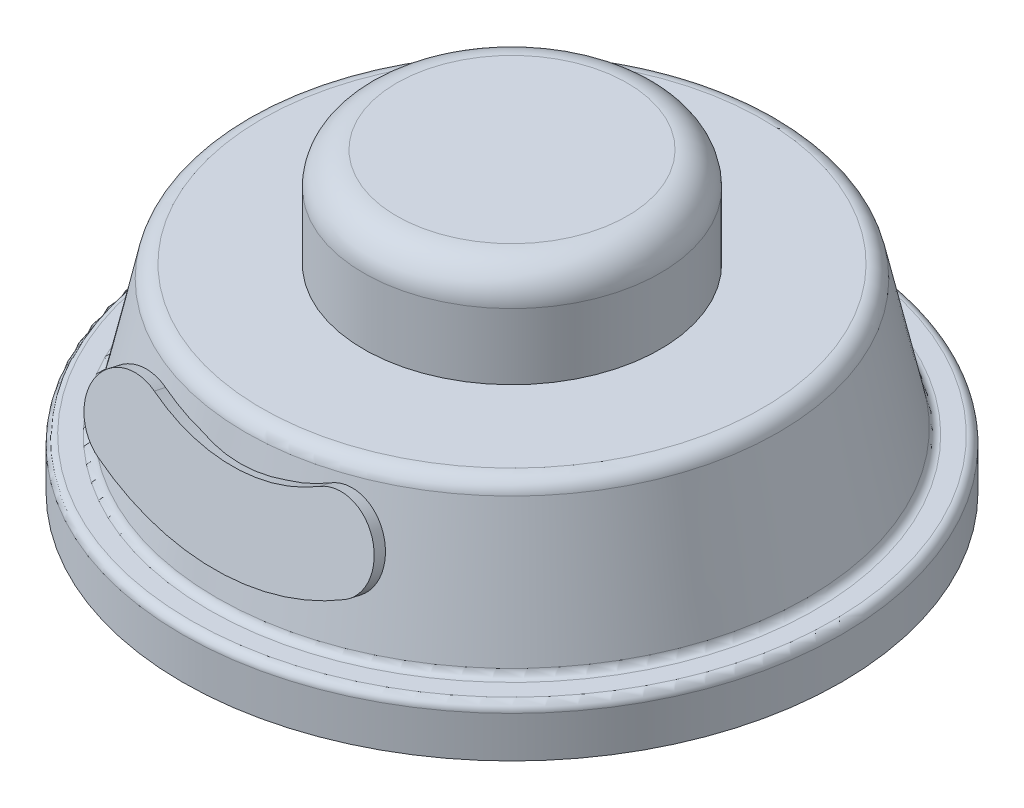
from build123d import *

# Parameters (mm, degrees)
SKETCH_1_R      = 20
EXTRUDE_1_DEPTH = 3
SKETCH_4_R      = 9
EXTRUDE_2_DEPTH = 6
FILLET_1_R      = 2
FILLET_2_R      = 1
FILLET_3_R      = 0.5
EXTRUDE_START   = -0.2
SKETCH_6_W      = 2
SKETCH_6_H      = 2
EXTRUDE_3_DEPTH = 0.7


with BuildPart() as part:
    # 草图1 → 凸台-拉伸1 (new body)
    with BuildSketch(Plane(origin=(0, 0, 0), x_dir=(1, 0, 0), z_dir=(0, 1, 0))):
        Circle(SKETCH_1_R)
    extrude(amount=EXTRUDE_1_DEPTH)

    # 草图3 → 旋转1 (revolve)
    with BuildSketch(Plane.XY):
        Polygon((0, 3), (-18, 3), (-16, 12), (0, 12), align=None)
    revolve(axis=Axis((0, 12, 0), (0, -1, 0)))

    # 草图4 → 凸台-拉伸2 (add)
    with BuildSketch(Plane(origin=(0, 12, 0), x_dir=(1, 0, 0), z_dir=(0, 1, 0))):
        Circle(SKETCH_4_R)
    extrude(amount=EXTRUDE_2_DEPTH)

    # 圆角1
    fillet_1_edges = [part.edges().sort_by_distance(p)[0] for p in [
        (-9, 18, 0),
    ]]
    fillet(fillet_1_edges, radius=FILLET_1_R)

    # 圆角2
    fillet_2_edges = [part.edges().sort_by_distance(p)[0] for p in [
        (16, 12, 0),
    ]]
    fillet(fillet_2_edges, radius=FILLET_2_R)

    # 草图5 → 切除-旋转1 (revolve, cut)
    with BuildSketch(Plane.XY):
        with BuildLine():
            Line((-17.5, 0), (-15, 0))
            ThreePointArc((-15, 0), (-16.767766953, 0.732233047), (-17.5, 2.5))
            Line((-17.5, 2.5), (-17.5, 0))
        make_face()
        with BuildLine():
            Line((-10, 3.5), (-13.370759884, 0.603799419))
            ThreePointArc((-13.370759884, 0.603799419), (-14.131236929, 0.155804887), (-15, 0))
            Line((-15, 0), (0, 0))
            Line((0, 0), (0, 2))
            ThreePointArc((0, 2), (-5.055937104, 2.377085973), (-10, 3.5))
        make_face()
    revolve(axis=Axis((0, 2, 0), (0, -1, 0)), mode=Mode.SUBTRACT)

    # 圆角3
    fillet_3_edges = [part.edges().sort_by_distance(p)[0] for p in [
        (-20, 3, 0),
        (18, 3, 0),
    ]]
    fillet(fillet_3_edges, radius=FILLET_3_R)

    # 草图6 → 凸台-拉伸3 (add)
    with BuildSketch(Plane(origin=(0, 3.952941176, 17.788235294), x_dir=(1, 0, 0), z_dir=(0, 0.216930458, 0.97618706)).offset(EXTRUDE_START)):
        with BuildLine():
            ThreePointArc((-7.488132587, 2.917536085), (0, 0.933042267), (7.488132587, 2.917536085))
            ThreePointArc((7.488132587, 2.917536085), (8.421871934, 6.327540606), (5.011867413, 7.261279953))
            ThreePointArc((5.011867413, 7.261279953), (0, 5.933042267), (-5.011867413, 7.261279953))
            ThreePointArc((-5.011867413, 7.261279953), (-8.421871934, 6.327540606), (-7.488132587, 2.917536085))
        make_face()
        with Locations((0, 3.433042267)):
            Rectangle(SKETCH_6_W, SKETCH_6_H, mode=Mode.SUBTRACT)
        with Locations((0, 3.433042267)):
            Rectangle(SKETCH_6_W, SKETCH_6_H)
    extrude(amount=EXTRUDE_3_DEPTH)


solid = part.part
